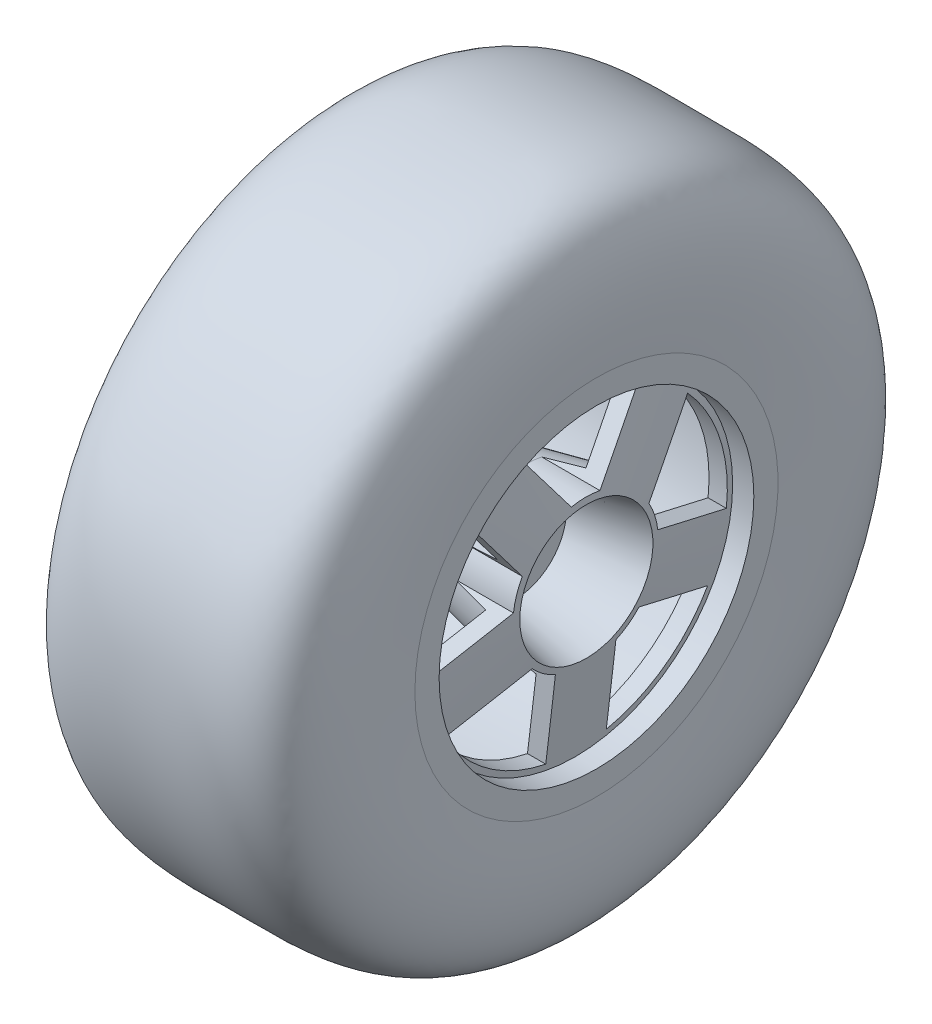
from build123d import *

# Parameters (mm, degrees)
CUT_EXTRUDE1_REACH = 32.2
SKETCH3_R          = 2.15
CUT_EXTRUDE2_REACH = 45.668
CUT_EXTRUDE3_DEPTH = 4


with BuildPart() as part:
    # Sketch2 → Revolve1 (revolve)
    with BuildSketch(Plane.XY):
        with BuildLine():
            Line((0, 0), (0, 9.871675482))
            Line((0, 9.871675482), (16.488909248, 13.365088458))
            Line((16.488909248, 13.365088458), (13.847020393, 35))
            Line((13.847020393, 35), (-22.2, 38.5))
            Line((-22.2, 38.5), (-22.2, 41.8))
            Line((-22.2, 41.8), (-21.7, 41.8))
            add(Edge.make_bspline(
                [(-21.7, 41.8), (-21.533718516, 55.260750985), (-4.008905518, 53.174245615), (23.517269043, 55.137002211), (21.925848048, 36.077457734), (21.468315468, 30)],
                knots=[0, 0, 0, 0, 0.416041418, 0.696055302, 1, 1, 1, 1], degree=3))
            Line((21.468315468, 30), (21.468315468, 26))
            Line((21.468315468, 26), (17.968315468, 26))
            Line((17.968315468, 26), (19.8, 11))
            Line((19.8, 11), (8, 8.5))
            Line((8, 8.5), (8, 0))
            Line((8, 0), (0, 0))
        make_face()
    revolve(axis=Axis((-63.183775164, 0, 0), (1, 0, 0)))

    # Sketch3 → Cut-Extrude1 (cut, up to next)
    with BuildSketch(Plane(origin=(8, 0, 0), x_dir=(0, 0, -1), z_dir=(1, 0, 0)), mode=Mode.PRIVATE) as cut_extrude1_sk1:
        Circle(SKETCH3_R)
    cut_extrude1_tool1 = extrude(cut_extrude1_sk1.sketch, amount=-CUT_EXTRUDE1_REACH, mode=Mode.PRIVATE) & part.part
    add(cut_extrude1_tool1.solids().sort_by_distance((8, 0, 0))[0], mode=Mode.SUBTRACT)

    # Sketch4 → Cut-Extrude2 (cut, up to next)
    with BuildSketch(Plane(origin=(21.468315468, 0, 0), x_dir=(0, 0, -1), z_dir=(1, 0, 0)), mode=Mode.PRIVATE) as cut_extrude2_sk1:
        with BuildLine():
            Line((-8.51429142, 20.225424859), (8.51429142, 20.225424859))
            Line((8.51429142, 20.225424859), (10.352654493, 22.755714556))
            ThreePointArc((10.352654493, 22.755714556), (0, 25), (-10.352654493, 22.755714556))
            Line((-10.352654493, 22.755714556), (-8.51429142, 20.225424859))
        make_face()
    cut_extrude2_tool1 = extrude(cut_extrude2_sk1.sketch, amount=-CUT_EXTRUDE2_REACH, mode=Mode.PRIVATE) & part.part
    add(cut_extrude2_tool1.solids().sort_by_distance((21.468315, 22.372787, 0))[0], mode=Mode.SUBTRACT)
    # Sketch4 → Cut-Extrude2 (cut, up to next)
    with BuildSketch(Plane(origin=(21.468315468, 0, 0), x_dir=(0, 0, -1), z_dir=(1, 0, 0)), mode=Mode.PRIVATE) as cut_extrude2_sk2:
        with BuildLine():
            Line((-8.51429142, 20.225424859), (-2.366895131, 11.764259749))
            ThreePointArc((-2.366895131, 11.764259749), (0, 12), (2.366895131, 11.764259749))
            Line((2.366895131, 11.764259749), (8.51429142, 20.225424859))
            Line((8.51429142, 20.225424859), (-8.51429142, 20.225424859))
        make_face()
    cut_extrude2_tool2 = extrude(cut_extrude2_sk2.sketch, amount=-CUT_EXTRUDE2_REACH, mode=Mode.PRIVATE) & part.part
    add(cut_extrude2_tool2.solids().sort_by_distance((21.468315, 16.831807, 0))[0], mode=Mode.SUBTRACT)
    # Sketch4 → Cut-Extrude2 (cut, up to next)
    with BuildSketch(Plane(origin=(21.468315468, 0, 0), x_dir=(0, 0, -1), z_dir=(1, 0, 0)), mode=Mode.PRIVATE) as cut_extrude2_sk3:
        with BuildLine():
            Line((16.604461364, 14.347572336), (21.866582851, -1.847572336))
            Line((21.866582851, -1.847572336), (24.841116787, -2.814056999))
            ThreePointArc((24.841116787, -2.814056999), (24.960247592, -1.409269374), (25, 0))
            ThreePointArc((25, 0), (23.303117934, 9.053435511), (18.442824436, 16.877862033))
            Line((18.442824436, 16.877862033), (16.604461364, 14.347572336))
        make_face()
    cut_extrude2_tool3 = extrude(cut_extrude2_sk3.sketch, amount=-CUT_EXTRUDE2_REACH, mode=Mode.PRIVATE) & part.part
    add(cut_extrude2_tool3.solids().sort_by_distance((21.468315, 6.913571, -21.277785))[0], mode=Mode.SUBTRACT)
    # Sketch4 → Cut-Extrude2 (cut, up to next)
    with BuildSketch(Plane(origin=(21.468315468, 0, 0), x_dir=(0, 0, -1), z_dir=(1, 0, 0)), mode=Mode.PRIVATE) as cut_extrude2_sk4:
        with BuildLine():
            Line((11.919886713, 1.384305151), (21.866582851, -1.847572336))
            Line((21.866582851, -1.847572336), (16.604461364, 14.347572336))
            Line((16.604461364, 14.347572336), (10.457065074, 5.886407226))
            ThreePointArc((10.457065074, 5.886407226), (11.412678196, 3.708203932), (11.919886713, 1.384305151))
        make_face()
    cut_extrude2_tool4 = extrude(cut_extrude2_sk4.sketch, amount=-CUT_EXTRUDE2_REACH, mode=Mode.PRIVATE) & part.part
    add(cut_extrude2_tool4.solids().sort_by_distance((21.468315, 5.201314, -16.007999))[0], mode=Mode.SUBTRACT)
    # Sketch4 → Cut-Extrude2 (cut, up to next)
    with BuildSketch(Plane(origin=(21.468315468, 0, 0), x_dir=(0, 0, -1), z_dir=(1, 0, 0)), mode=Mode.PRIVATE) as cut_extrude2_sk5:
        with BuildLine():
            Line((18.776412907, -11.358137499), (5, -21.36728736))
            Line((5, -21.36728736), (5, -24.494897428))
            ThreePointArc((5, -24.494897428), (14.694631307, -20.225424859), (21.750946843, -12.324622162))
            Line((21.750946843, -12.324622162), (18.776412907, -11.358137499))
        make_face()
    cut_extrude2_tool5 = extrude(cut_extrude2_sk5.sketch, amount=-CUT_EXTRUDE2_REACH, mode=Mode.PRIVATE) & part.part
    add(cut_extrude2_tool5.solids().sort_by_distance((21.468315, -18.099965, -13.150394))[0], mode=Mode.SUBTRACT)
    # Sketch4 → Cut-Extrude2 (cut, up to next)
    with BuildSketch(Plane(origin=(21.468315468, 0, 0), x_dir=(0, 0, -1), z_dir=(1, 0, 0)), mode=Mode.PRIVATE) as cut_extrude2_sk6:
        with BuildLine():
            Line((5, -10.908712115), (5, -21.36728736))
            Line((5, -21.36728736), (18.776412907, -11.358137499))
            Line((18.776412907, -11.358137499), (8.829716769, -8.126260012))
            ThreePointArc((8.829716769, -8.126260012), (7.053423028, -9.708203932), (5, -10.908712115))
        make_face()
    cut_extrude2_tool6 = extrude(cut_extrude2_sk6.sketch, amount=-CUT_EXTRUDE2_REACH, mode=Mode.PRIVATE) & part.part
    add(cut_extrude2_tool6.solids().sort_by_distance((21.468315, -13.617218, -9.893488))[0], mode=Mode.SUBTRACT)
    # Sketch4 → Cut-Extrude2 (cut, up to next)
    with BuildSketch(Plane(origin=(21.468315468, 0, 0), x_dir=(0, 0, -1), z_dir=(1, 0, 0)), mode=Mode.PRIVATE) as cut_extrude2_sk7:
        with BuildLine():
            Line((-5, -24.494897428), (-5, -21.36728736))
            Line((-5, -21.36728736), (-18.776412907, -11.358137499))
            Line((-18.776412907, -11.358137499), (-21.750946843, -12.324622162))
            ThreePointArc((-21.750946843, -12.324622162), (-14.694631307, -20.225424859), (-5, -24.494897428))
        make_face()
    cut_extrude2_tool7 = extrude(cut_extrude2_sk7.sketch, amount=-CUT_EXTRUDE2_REACH, mode=Mode.PRIVATE) & part.part
    add(cut_extrude2_tool7.solids().sort_by_distance((21.468315, -18.099965, 13.150394))[0], mode=Mode.SUBTRACT)
    # Sketch4 → Cut-Extrude2 (cut, up to next)
    with BuildSketch(Plane(origin=(21.468315468, 0, 0), x_dir=(0, 0, -1), z_dir=(1, 0, 0)), mode=Mode.PRIVATE) as cut_extrude2_sk8:
        with BuildLine():
            Line((-18.776412907, -11.358137499), (-5, -21.36728736))
            Line((-5, -21.36728736), (-5, -10.908712115))
            ThreePointArc((-5, -10.908712115), (-7.053423028, -9.708203932), (-8.829716769, -8.126260012))
            Line((-8.829716769, -8.126260012), (-18.776412907, -11.358137499))
        make_face()
    cut_extrude2_tool8 = extrude(cut_extrude2_sk8.sketch, amount=-CUT_EXTRUDE2_REACH, mode=Mode.PRIVATE) & part.part
    add(cut_extrude2_tool8.solids().sort_by_distance((21.468315, -13.617218, 9.893488))[0], mode=Mode.SUBTRACT)
    # Sketch4 → Cut-Extrude2 (cut, up to next)
    with BuildSketch(Plane(origin=(21.468315468, 0, 0), x_dir=(0, 0, -1), z_dir=(1, 0, 0)), mode=Mode.PRIVATE) as cut_extrude2_sk9:
        with BuildLine():
            Line((-24.841116787, -2.814056999), (-21.866582851, -1.847572336))
            Line((-21.866582851, -1.847572336), (-16.604461364, 14.347572336))
            Line((-16.604461364, 14.347572336), (-18.442824436, 16.877862033))
            ThreePointArc((-18.442824436, 16.877862033), (-23.776412907, 7.725424859), (-24.841116787, -2.814056999))
        make_face()
    cut_extrude2_tool9 = extrude(cut_extrude2_sk9.sketch, amount=-CUT_EXTRUDE2_REACH, mode=Mode.PRIVATE) & part.part
    add(cut_extrude2_tool9.solids().sort_by_distance((21.468315, 6.913571, 21.277785))[0], mode=Mode.SUBTRACT)
    # Sketch4 → Cut-Extrude2 (cut, up to next)
    with BuildSketch(Plane(origin=(21.468315468, 0, 0), x_dir=(0, 0, -1), z_dir=(1, 0, 0)), mode=Mode.PRIVATE) as cut_extrude2_sk10:
        with BuildLine():
            Line((-16.604461364, 14.347572336), (-21.866582851, -1.847572336))
            Line((-21.866582851, -1.847572336), (-11.919886713, 1.384305151))
            ThreePointArc((-11.919886713, 1.384305151), (-11.412678196, 3.708203932), (-10.457065074, 5.886407226))
            Line((-10.457065074, 5.886407226), (-16.604461364, 14.347572336))
        make_face()
    cut_extrude2_tool10 = extrude(cut_extrude2_sk10.sketch, amount=-CUT_EXTRUDE2_REACH, mode=Mode.PRIVATE) & part.part
    add(cut_extrude2_tool10.solids().sort_by_distance((21.468315, 5.201314, 16.007999))[0], mode=Mode.SUBTRACT)

    # Sketch5 → Cut-Extrude3 (cut)
    with BuildSketch(Plane.ZY):
        Polygon((0, -6.92820323), (6, -3.464101615), (6, 3.464101615), (0, 6.92820323), (-6, 3.464101615), (-6, -3.464101615), align=None)
    extrude(amount=-CUT_EXTRUDE3_DEPTH, mode=Mode.SUBTRACT)


solid = part.part
